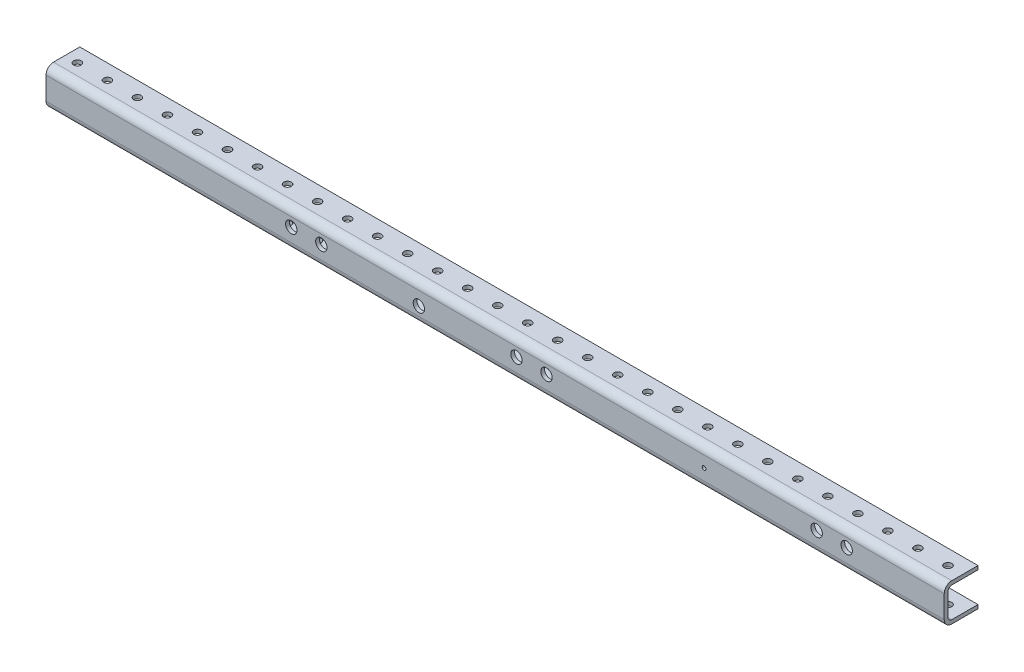
from build123d import *

# Parameters (mm, degrees)
SKETCH1_W          = 889
SKETCH1_H          = 31.75
EXTRUDE1_DEPTH     = 28.575
EXTRUDE2_REACH     = 891
SKETCH2_W          = 25.4
SKETCH2_H          = 25.4
HOLE1_D            = 6.35
HOLE1_DEPTH        = 3.175
LPATTERN1_COUNT    = 35
LPATTERN1_PITCH    = 25.4
HOLE2_D            = 9.652
HOLE2_DEPTH        = 3.175
LPATTERN2_COUNT    = 12
LPATTERN2_PITCH    = 25.4
HOLE3_D            = 9.652
HOLE3_DEPTH        = 3.175
HOLE4_D            = 9.652
HOLE4_DEPTH        = 3.175
LPATTERN3_COUNT    = 12
LPATTERN3_PITCH    = 25.4
HOLE5_D            = 3.175
HOLE5_DEPTH        = 3.175
HOLE6_D            = 6.35
HOLE6_DEPTH        = 3.175
LPATTERN4_COUNT    = 35
LPATTERN4_PITCH    = 25.4
FILLET1_R          = 3.175
FILLET2_R          = 3.175
FILLET3_R          = 6.35
FILLET4_R          = 6.35
SKETCH16_W         = 145.760071232
SKETCH16_H         = 71.504803879
CUT_EXTRUDE2_DEPTH = 75


with BuildPart() as part:
    # Sketch1 → Extrude1 (new body)
    with BuildSketch(Plane.XY.offset(3.175)):
        with Locations((428.480011997, 8.672957166)):
            Rectangle(SKETCH1_W, SKETCH1_H)
    extrude(amount=-EXTRUDE1_DEPTH)

    # Sketch2 → Extrude2 (cut, up to next)
    with BuildSketch(Plane.ZY.offset(16.019988003), mode=Mode.PRIVATE) as extrude2_sk1:
        with Locations((-12.7, 8.672957166)):
            Rectangle(SKETCH2_W, SKETCH2_H)
    extrude2_tool1 = extrude(extrude2_sk1.sketch, amount=-EXTRUDE2_REACH, mode=Mode.PRIVATE) & part.part
    add(extrude2_tool1.solids().sort_by_distance((-16.019988, 8.672957, -12.7))[0], mode=Mode.SUBTRACT)

    # Hole1
    with Locations(Plane(origin=(0, 24.547957166, 0), x_dir=(-1, 0, 0), z_dir=(0, 1, 0))):
        with Locations((3.319988003, -12.7)):
            hole1 = Hole(HOLE1_D / 2, depth=HOLE1_DEPTH)

    # LPattern1: Hole1 ×35
    with Locations(*[(i * LPATTERN1_PITCH, 0, 0) for i in range(1, LPATTERN1_COUNT)]):
        add(hole1, mode=Mode.SUBTRACT)

    # Hole2
    with Locations(Plane.XY.offset(3.175)):
        with Locations((66.530011997, 10.577957166)):
            hole2 = Hole(HOLE2_D / 2, depth=HOLE2_DEPTH)

    # LPattern2: Hole2 ×12, 8 skipped
    with Locations(*[(i * LPATTERN2_PITCH, 0, 0) for i in range(1, LPATTERN2_COUNT) if i not in (2, 3, 4, 5, 6, 7, 8, 9)]):
        add(hole2, mode=Mode.SUBTRACT)

    # Hole3
    with Locations(Plane.XY.offset(3.175)):
        with Locations((428.480011997, 6.767957166)):
            Hole(HOLE3_D / 2, depth=HOLE3_DEPTH)

    # Hole4
    with Locations(Plane.XY.offset(3.175)):
        with Locations((511.030011997, 10.577957166)):
            hole4 = Hole(HOLE4_D / 2, depth=HOLE4_DEPTH)

    # LPattern3: Hole4 ×12, 8 skipped
    with Locations(*[(i * LPATTERN3_PITCH, 0, 0) for i in range(1, LPATTERN3_COUNT) if i not in (2, 3, 4, 5, 6, 7, 8, 9)]):
        add(hole4, mode=Mode.SUBTRACT)

    # Hole5
    with Locations(Plane.XY.offset(3.175)):
        with Locations((669.780011997, 8.672957166)):
            Hole(HOLE5_D / 2, depth=HOLE5_DEPTH)

    # Hole6
    with Locations(Plane(origin=(0, -4.027042834, 0), x_dir=(-1, 0, 0), z_dir=(0, 1, 0))):
        with Locations((3.319988003, -12.7)):
            hole6 = Hole(HOLE6_D / 2, depth=HOLE6_DEPTH)

    # LPattern4: Hole6 ×35
    with Locations(*[(i * LPATTERN4_PITCH, 0, 0) for i in range(1, LPATTERN4_COUNT)]):
        add(hole6, mode=Mode.SUBTRACT)

    # Fillet1
    fillet1_edges = [part.edges().sort_by_distance(p)[0] for p in [
        (428.480011997, 21.372957166, 0),
    ]]
    fillet(fillet1_edges, radius=FILLET1_R)

    # Fillet2
    fillet2_edges = [part.edges().sort_by_distance(p)[0] for p in [
        (428.480011997, -4.027042834, 0),
    ]]
    fillet(fillet2_edges, radius=FILLET2_R)

    # Fillet3
    fillet3_edges = [part.edges().sort_by_distance(p)[0] for p in [
        (428.480011997, -7.202042834, 3.175),
    ]]
    fillet(fillet3_edges, radius=FILLET3_R)

    # Fillet4
    fillet4_edges = [part.edges().sort_by_distance(p)[0] for p in [
        (428.480011997, 24.547957166, 3.175),
    ]]
    fillet(fillet4_edges, radius=FILLET4_R)

    # Sketch16 → Cut-Extrude2 (cut)
    with BuildSketch(Plane(origin=(0, 24.547957166, 0), x_dir=(1, 0, 0), z_dir=(0, 1, 0))):
        with Locations((40.099976381, -10.352401939)):
            Rectangle(SKETCH16_W, SKETCH16_H)
    extrude(amount=-CUT_EXTRUDE2_DEPTH, mode=Mode.SUBTRACT)


solid = part.part
